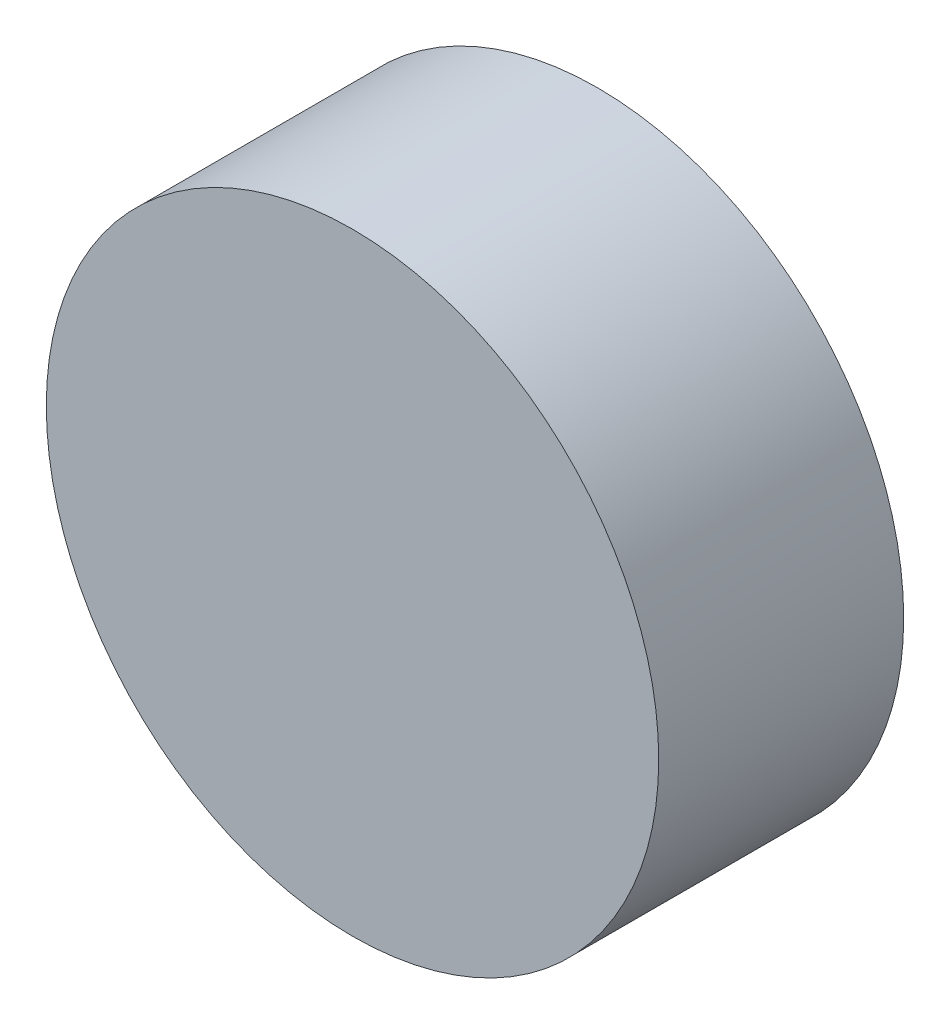
from build123d import *

# Parameters (mm, degrees)
SKETCH_1_R      = 50
EXTRUDE_1_DEPTH = 40


with BuildPart() as part:
    # 草图1 → 凸台-拉伸1 (new body)
    with BuildSketch(Plane.XY):
        Circle(SKETCH_1_R)
    extrude(amount=EXTRUDE_1_DEPTH)


solid = part.part
